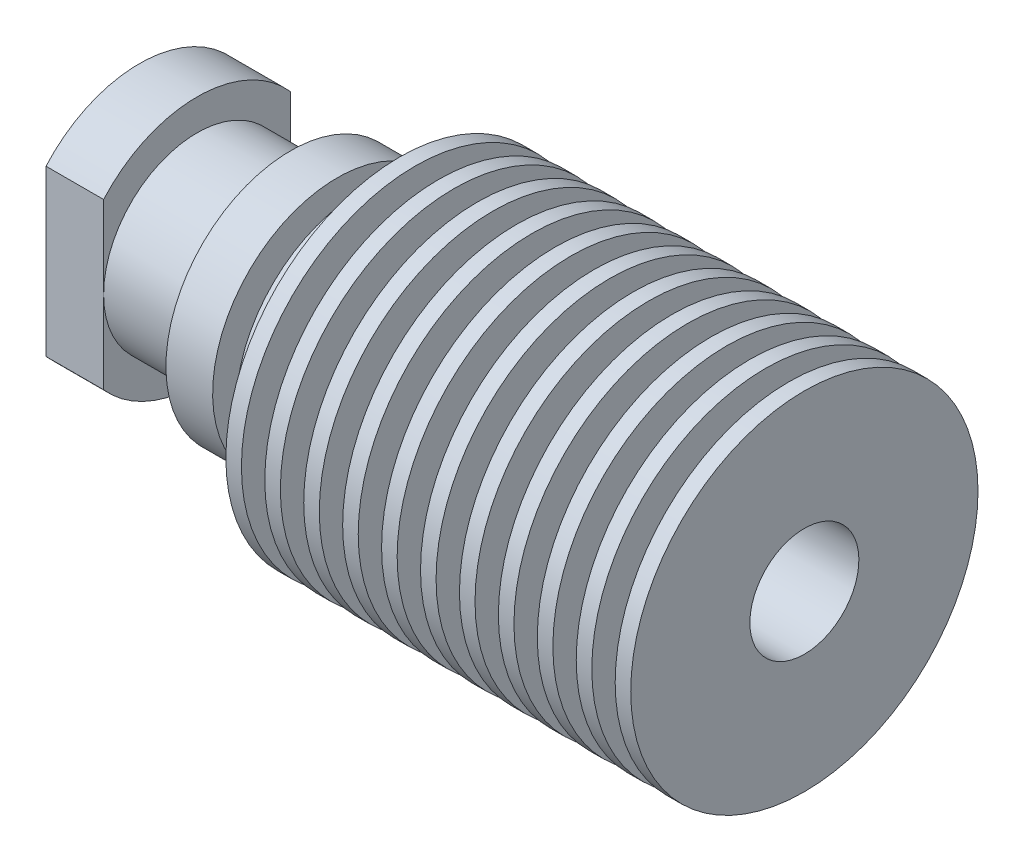
from build123d import *

# Parameters (mm, degrees)
CUT_EXTRUDE1_REACH = 44.7


with BuildPart() as part:
    # Sketch1 → Revolve1 (revolve)
    with BuildSketch(Plane.XY):
        Polygon((42.7, -3.5), (42.7, -11.15), (41.7, -11.15), (41.7, -6), (40.2, -6), (40.2, -11.15), (39.2, -11.15), (39.2, -5.868980552), (37.7, -5.868980552), (37.7, -11.15), (36.7, -11.15), (36.7, -5.737961104), (35.2, -5.737961104), (35.2, -11.15), (34.2, -11.15), (34.2, -5.606941655), (32.7, -5.606941655), (32.7, -11.15), (31.7, -11.15), (31.7, -5.475922207), (30.2, -5.475922207), (30.2, -11.15), (29.2, -11.15), (29.2, -5.344902759), (27.7, -5.344902759), (27.7, -11.15), (26.7, -11.15), (26.7, -5.213883311), (25.2, -5.213883311), (25.2, -11.15), (24.2, -11.15), (24.2, -5.082863863), (22.7, -5.082863863), (22.7, -11.15), (21.7, -11.15), (21.7, -4.951844414), (20.2, -4.951844414), (20.2, -11.15), (19.2, -11.15), (19.2, -4.820824966), (17.7, -4.820824966), (17.7, -11.15), (16.7, -11.15), (16.7, -4.689805518), (15.2, -4.689805518), (15.2, -8), (14.2, -8), (14.2, -4.689805518), (12.7, -4.689805518), (12.7, -8), (9.7, -8), (9.7, -6), (3.7, -6), (3.7, -8), (0, -8), (0, -4), (6.1, -4), (8, -2.1), (28, -2.1), (29.4, -3.5), align=None)
    revolve(axis=Axis((0, 0, 0), (1, 0, 0)))

    # Sketch2 → Cut-Extrude1 (cut, up to next)
    with BuildSketch(Plane.ZY, mode=Mode.PRIVATE) as cut_extrude1_sk1:
        with BuildLine():
            Line((6, 5.291502622), (6, -5.291502622))
            ThreePointArc((6, -5.291502622), (8, 0), (6, 5.291502622))
        make_face()
    cut_extrude1_tool1 = extrude(cut_extrude1_sk1.sketch, amount=-CUT_EXTRUDE1_REACH, mode=Mode.PRIVATE) & part.part
    add(cut_extrude1_tool1.solids().sort_by_distance((0, 0, 6.809243))[0], mode=Mode.SUBTRACT)
    # Sketch2 → Cut-Extrude1 (cut, up to next)
    with BuildSketch(Plane.ZY, mode=Mode.PRIVATE) as cut_extrude1_sk2:
        with BuildLine():
            Line((-6, 5.291502622), (-6, -5.291502622))
            ThreePointArc((-6, -5.291502622), (-8, 0), (-6, 5.291502622))
        make_face()
    cut_extrude1_tool2 = extrude(cut_extrude1_sk2.sketch, amount=-CUT_EXTRUDE1_REACH, mode=Mode.PRIVATE) & part.part
    add(cut_extrude1_tool2.solids().sort_by_distance((0, 0, -6.809243))[0], mode=Mode.SUBTRACT)


solid = part.part
